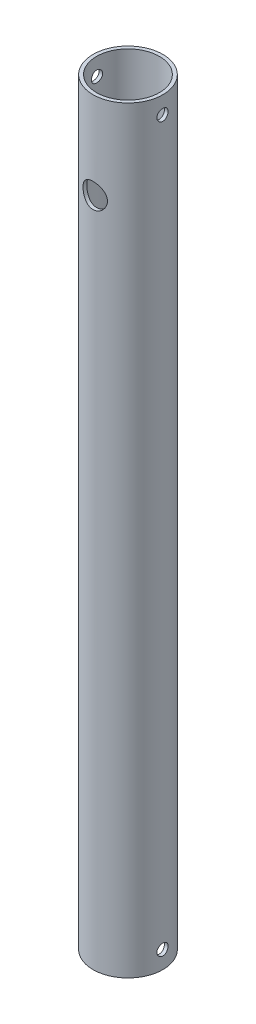
from build123d import *

# Parameters (mm, degrees)
SKETCH1_R            = 10
SKETCH1_R_2          = 9
BOSS_EXTRUDE1_DEPTH  = 217
M3_CLEARANCE_HOLE1_D = 3.2
CUT_EXTRUDE1_REACH   = 220.149
SKETCH4_R            = 3.5
CUT_EXTRUDE2_REACH   = 220.149
SKETCH5_R            = 3.5


with BuildPart() as part:
    # Sketch1 → Boss-Extrude1 (new body)
    with BuildSketch(Plane(origin=(0, 0, 0), x_dir=(1, 0, 0), z_dir=(0, 1, 0))):
        Circle(SKETCH1_R)
        Circle(SKETCH1_R_2, mode=Mode.SUBTRACT)
    extrude(amount=BOSS_EXTRUDE1_DEPTH)

    # M3 Clearance Hole1 (through all)
    with Locations(Plane.ZY.offset(10)):
        with Locations((0, 5)):
            m3_clearance_hole1 = Hole(M3_CLEARANCE_HOLE1_D / 2)

    # Mirror1: M3 Clearance Hole1 across plane
    add(m3_clearance_hole1.mirror(Plane.ZX.offset(108.5)), mode=Mode.SUBTRACT)

    # Sketch4 → Cut-Extrude1 (cut, up to next)
    with BuildSketch(Plane(origin=(0, 0, -10), x_dir=(-1, 0, 0), z_dir=(0, 0, -1)), mode=Mode.PRIVATE) as cut_extrude1_sk1:
        with Locations((0, 25)):
            Circle(SKETCH4_R)
    cut_extrude1_tool1 = extrude(cut_extrude1_sk1.sketch, amount=-CUT_EXTRUDE1_REACH, mode=Mode.PRIVATE) & part.part
    add(cut_extrude1_tool1.solids().sort_by_distance((0, 25, -10))[0], mode=Mode.SUBTRACT)

    # Sketch5 → Cut-Extrude2 (cut, up to next)
    with BuildSketch(Plane.XY.offset(10), mode=Mode.PRIVATE) as cut_extrude2_sk1:
        with Locations((0, 192)):
            Circle(SKETCH5_R)
    cut_extrude2_tool1 = extrude(cut_extrude2_sk1.sketch, amount=-CUT_EXTRUDE2_REACH, mode=Mode.PRIVATE) & part.part
    add(cut_extrude2_tool1.solids().sort_by_distance((0, 192, 10))[0], mode=Mode.SUBTRACT)


solid = part.part
